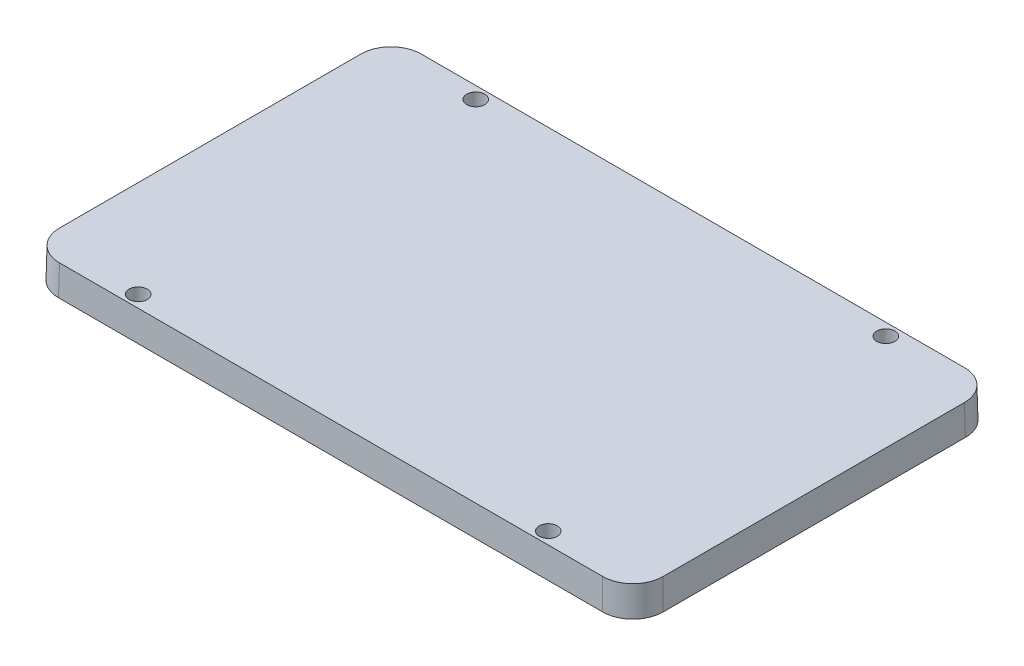
from build123d import *

# Parameters (mm, degrees)
SKETCH1_W               = 100
SKETCH1_H               = 60
BOSS_EXTRUDE1_DEPTH     = 5
BOSS_EXTRUDE1_TAPER     = 1
FILLET1_R               = 5
SKETCH2_R               = 1.5
CUT_EXTRUDE1_DEPTH      = 5
CUT_EXTRUDE1_TAPER      = -1
MIRROR2_COPY_1_SKETCH_R = 1.5
MIRROR2_COPY_1_DEPTH    = 5
MIRROR2_COPY_1_TAPER    = -1
SCALE1_SCALE            = 1.05


with BuildPart() as part:
    # Sketch1 → Boss-Extrude1 (new body)
    with BuildSketch(Plane(origin=(0, 0, 0), x_dir=(1, 0, 0), z_dir=(0, 1, 0))):
        Rectangle(SKETCH1_W, SKETCH1_H)
    extrude(amount=BOSS_EXTRUDE1_DEPTH, taper=BOSS_EXTRUDE1_TAPER)

    # Fillet1
    fillet1_edges = [part.edges().sort_by_distance(p)[0] for p in [
        (49.956362338, 2.5, 29.956362338),
        (-49.956362338, 2.5, 29.956362338),
        (-49.956362338, 2.5, -29.956362338),
        (49.956362338, 2.5, -29.956362338),
    ]]
    fillet(fillet1_edges, radius=FILLET1_R)

    # Sketch2 → Cut-Extrude1 (cut)
    with BuildSketch(Plane(origin=(0, 5, 0), x_dir=(1, 0, 0), z_dir=(0, 1, 0))):
        with Locations((33.912724675, -27.912724675)):
            Circle(SKETCH2_R)
    cut_extrude1 = extrude(amount=-CUT_EXTRUDE1_DEPTH, taper=CUT_EXTRUDE1_TAPER, mode=Mode.SUBTRACT)

    # Mirror1: Cut-Extrude1 across plane
    add(cut_extrude1.mirror(Plane.XY), mode=Mode.SUBTRACT)

    # Mirror2: Cut-Extrude1 across plane
    add(cut_extrude1.mirror(Plane(origin=(0, 0, 0), x_dir=(0, 0, 1), z_dir=(1, 0, 0))), mode=Mode.SUBTRACT)

    # Mirror2 copy 1 sketch → Mirror2 copy 1 (cut)
    with BuildSketch(Plane(origin=(0, 5, 0), x_dir=(-1, 0, 0), z_dir=(0, 1, 0))):
        with Locations((33.912724675, -27.912724675)):
            Circle(MIRROR2_COPY_1_SKETCH_R)
    extrude(amount=-MIRROR2_COPY_1_DEPTH, taper=MIRROR2_COPY_1_TAPER, mode=Mode.SUBTRACT)


with BuildPart() as part_1:
    # Scale1: scaled about (-4.1e-08, 2.498279052, 6.8e-08)
    add(part.part.scale(SCALE1_SCALE).moved(Location((2e-09, -0.124913953, -3e-09))))


solid = part_1.part
